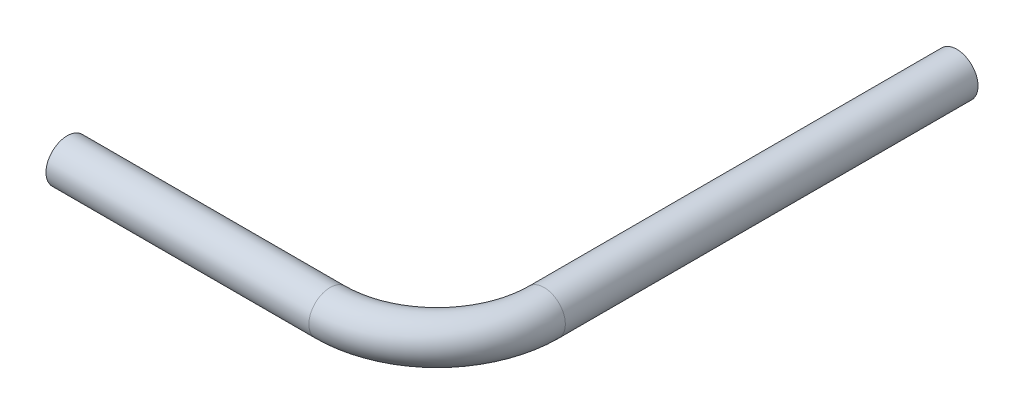
from build123d import *

# Parameters (mm, degrees)
SKETCH2_R   = 3.175
SKETCH2_R_2 = 2.4638


with BuildPart() as part:
    # Sweep-Thin1: sweep along a path in Sketch3
    with BuildLine(Plane(origin=(0, 0, 0), x_dir=(1, 0, 0), z_dir=(0, 1, 0))) as sweep_thin1_path:
        Line((0, 0), (39.3, 0))
        ThreePointArc((39.3, 0), (50.613708499, 4.686291501), (55.3, 16))
        Line((55.3, 16), (55.3, 77.69897428))
    # Sketch2 → Sweep-Thin1 (sweep)
    with BuildSketch(Plane(origin=(0, 0, 0), x_dir=(0, 0, -1), z_dir=(1, 0, 0))):
        Circle(SKETCH2_R)
        Circle(SKETCH2_R_2, mode=Mode.SUBTRACT)
    sweep(path=sweep_thin1_path.line)


solid = part.part
